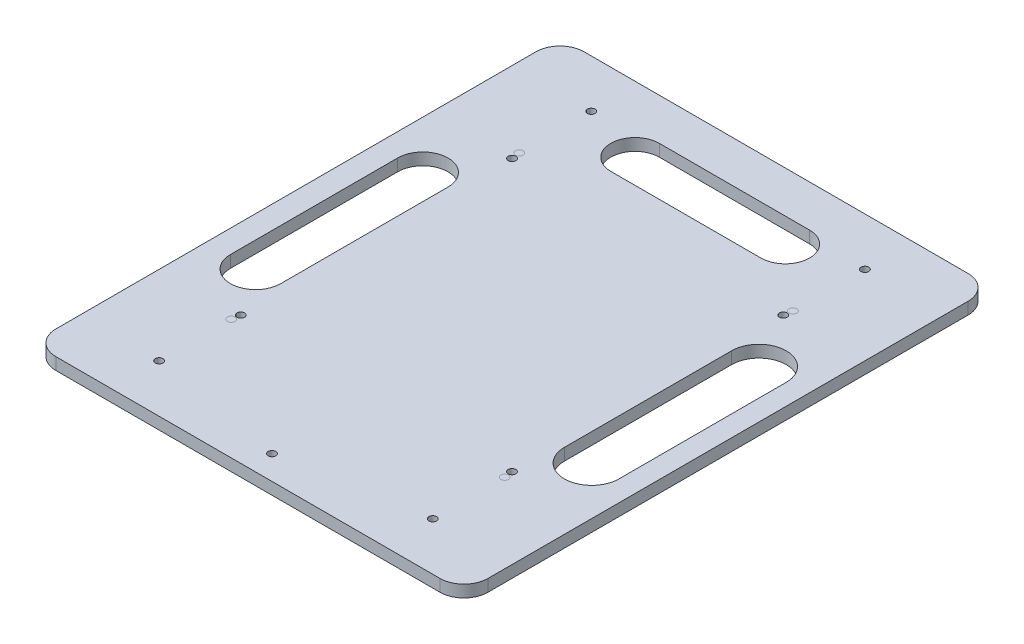
from build123d import *

# Parameters (mm, degrees)
SKETCH_1_R          = 1.6
EXTRUDE_1_DEPTH     = 5
SKETCH_4_R          = 1.6
CUT_EXTRUDE_2_DEPTH = 10
SKETCH_5_R          = 1.6
EXTRUDE_3_DEPTH     = 5
EXTRUDE_3_2_DEPTH   = 5
EXTRUDE_3_3_DEPTH   = 5
EXTRUDE_3_4_DEPTH   = 5
SKETCH_6_R          = 1.6
CUT_EXTRUDE_3_DEPTH = 5
SKETCH_8_R          = 1.6
CUT_EXTRUDE_4_DEPTH = 5
CUT_EXTRUDE_5_DEPTH = 10


with BuildPart() as part:
    # 草图1 → 凸台-拉伸1 (new body)
    with BuildSketch(Plane(origin=(0, 0, 0), x_dir=(1, 0, 0), z_dir=(0, 1, 0))):
        with BuildLine():
            Line((-104.074074074, 85.341130604), (55.925925926, 85.341130604))
            ThreePointArc((55.925925926, 85.341130604), (62.996993738, 82.412198416), (65.925925926, 75.341130604))
            Line((65.925925926, 75.341130604), (65.925925926, -124.658869396))
            ThreePointArc((65.925925926, -124.658869396), (62.996993738, -131.729937208), (55.925925926, -134.658869396))
            Line((55.925925926, -134.658869396), (-104.074074074, -134.658869396))
            ThreePointArc((-104.074074074, -134.658869396), (-111.145141886, -131.729937208), (-114.074074074, -124.658869396))
            Line((-114.074074074, -124.658869396), (-114.074074074, 75.341130604))
            ThreePointArc((-114.074074074, 75.341130604), (-111.145141886, 82.412198416), (-104.074074074, 85.341130604))
        make_face()
        with Locations((-81.074074074, 35.341130604)):
            Circle(SKETCH_1_R, mode=Mode.SUBTRACT)
        with Locations((32.925925926, 35.341130604)):
            Circle(SKETCH_1_R, mode=Mode.SUBTRACT)
        with Locations((32.925925926, -84.658869396)):
            Circle(SKETCH_1_R, mode=Mode.SUBTRACT)
        with Locations((-81.074074074, -84.658869396)):
            Circle(SKETCH_1_R, mode=Mode.SUBTRACT)
    extrude(amount=EXTRUDE_1_DEPTH)

    # 草图4 → 切除-拉伸2 (cut)
    with BuildSketch(Plane(origin=(0, 5, 0), x_dir=(1, 0, 0), z_dir=(0, 1, 0))):
        with Locations((-81.074074074, 65.341130604)):
            Circle(SKETCH_4_R)
        with Locations((32.925925926, 65.341130604)):
            Circle(SKETCH_4_R)
        with Locations((-81.074074074, -114.658869396)):
            Circle(SKETCH_4_R)
        with Locations((32.925925926, -114.658869396)):
            Circle(SKETCH_4_R)
    extrude(amount=-CUT_EXTRUDE_2_DEPTH, mode=Mode.SUBTRACT)

    # 草图6 → 切除-拉伸3 (cut)
    with BuildSketch(Plane(origin=(0, 5, 0), x_dir=(1, 0, 0), z_dir=(0, 1, 0))):
        with Locations((-80.574074074, -81.158869396)):
            Circle(SKETCH_6_R)
        with Locations((-80.574074074, 31.841130604)):
            Circle(SKETCH_6_R)
        with Locations((32.425925926, 31.841130604)):
            Circle(SKETCH_6_R)
        with Locations((32.425925926, -81.158869396)):
            Circle(SKETCH_6_R)
    extrude(amount=-CUT_EXTRUDE_3_DEPTH, mode=Mode.SUBTRACT)

    # 草图8 → 切除-拉伸4 (cut)
    with BuildSketch(Plane.XZ):
        with Locations((-24.074074074, 124.658869396)):
            Circle(SKETCH_8_R)
    extrude(amount=-CUT_EXTRUDE_4_DEPTH, mode=Mode.SUBTRACT)

    # 草图9 → 切除-拉伸5 (cut)
    with BuildSketch(Plane.XZ):
        with BuildLine():
            Line((-83.583774313, 61.461195306), (-83.583774313, -8.202630081))
            ThreePointArc((-83.583774313, -8.202630081), (-94.074074074, -18.692929841), (-104.564373835, -8.202630081))
            Line((-104.564373835, -8.202630081), (-104.564373835, 61.461195306))
            ThreePointArc((-104.564373835, 61.461195306), (-94.074074074, 71.951495067), (-83.583774313, 61.461195306))
        make_face()
        with BuildLine():
            Line((57.303514341, 61.461195306), (57.303514341, -8.202630081))
            ThreePointArc((57.303514341, -8.202630081), (45.925925926, -19.580218496), (34.54833751, -8.202630081))
            Line((34.54833751, -8.202630081), (34.54833751, 61.461195306))
            ThreePointArc((34.54833751, 61.461195306), (45.925925926, 72.838783721), (57.303514341, 61.461195306))
        make_face()
        with BuildLine():
            Line((-55.348114705, -47.763685582), (7.227090262, -47.763685582))
            ThreePointArc((7.227090262, -47.763685582), (17.335582771, -57.87217809), (7.227090262, -67.980670599))
            Line((7.227090262, -67.980670599), (-55.348114705, -67.980670599))
            ThreePointArc((-55.348114705, -67.980670599), (-65.456607213, -57.87217809), (-55.348114705, -47.763685582))
        make_face()
    extrude(amount=-CUT_EXTRUDE_5_DEPTH, mode=Mode.SUBTRACT)


with BuildPart() as body_2:
    # 草图5 → 凸台-拉伸3 (new body)
    with BuildSketch(Plane(origin=(0, 5, 0), x_dir=(1, 0, 0), z_dir=(0, 1, 0))):
        with Locations((-81.074074074, 35.341130604)):
            Circle(SKETCH_5_R)
    extrude(amount=-EXTRUDE_3_DEPTH)


with BuildPart() as body_3:
    # 草图5 → Extrude 3 2 (new body)
    with BuildSketch(Plane(origin=(0, 5, 0), x_dir=(1, 0, 0), z_dir=(0, 1, 0))):
        with Locations((32.925925926, 35.341130604)):
            Circle(SKETCH_5_R)
    extrude(amount=-EXTRUDE_3_2_DEPTH)


with BuildPart() as body_4:
    # 草图5 → Extrude 3 3 (new body)
    with BuildSketch(Plane(origin=(0, 5, 0), x_dir=(1, 0, 0), z_dir=(0, 1, 0))):
        with Locations((32.925925926, -84.658869396)):
            Circle(SKETCH_5_R)
    extrude(amount=-EXTRUDE_3_3_DEPTH)


with BuildPart() as body_5:
    # 草图5 → Extrude 3 4 (new body)
    with BuildSketch(Plane(origin=(0, 5, 0), x_dir=(1, 0, 0), z_dir=(0, 1, 0))):
        with Locations((-81.074074074, -84.658869396)):
            Circle(SKETCH_5_R)
    extrude(amount=-EXTRUDE_3_4_DEPTH)


solid = Compound([part.part, body_2.part, body_3.part, body_4.part, body_5.part])
